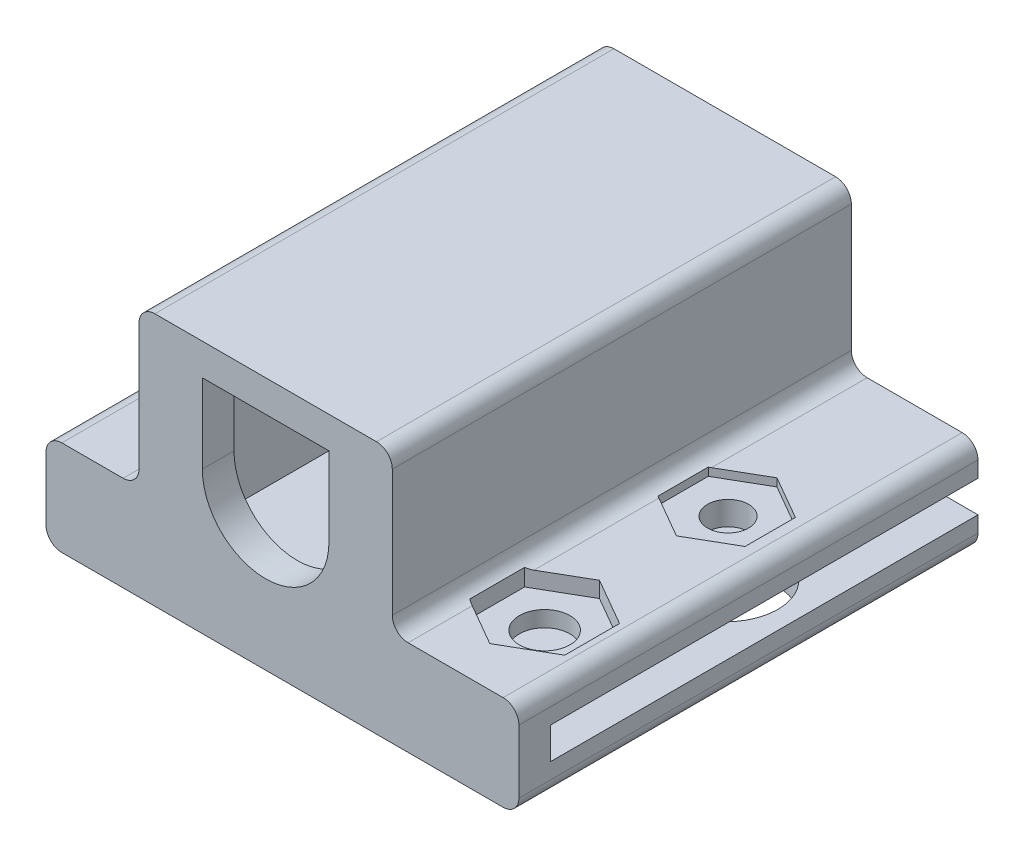
from build123d import *

# Parameters (mm, degrees)
EXTRUDE_1_DEPTH          = 2
EXTRUDE_2_DEPTH          = 27
SKETCH_4_R               = 3.227350269
CUT_EXTRUDE_1_DEPTH      = 2
CUT_EXTRUDE_2_DEPTH      = 11
CUT_EXTRUDE_2_DEPTH_BACK = 0.5
CUT_EXTRUDE_3_DEPTH      = 11
CUT_EXTRUDE_3_DEPTH_BACK = 1
SKETCH_8_W               = 12
SKETCH_8_H               = 1
EXTRUDE_3_DEPTH          = 1.6
SKETCH_10_R              = 1.6
CUT_EXTRUDE_4_DEPTH      = 6
SKETCH_11_R              = 1.3
CUT_EXTRUDE_5_DEPTH      = 6.5


with BuildPart() as part:
    # 草图1 → 凸台-拉伸1 (new body)
    with BuildSketch(Plane.XY):
        with BuildLine():
            Line((-9, -3), (-12.875, -3))
            ThreePointArc((-12.875, -3), (-13.582106781, -3.292893219), (-13.875, -4))
            Line((-13.875, -4), (-13.875, -8))
            ThreePointArc((-13.875, -8), (-13.582106781, -8.707106781), (-12.875, -9))
            Line((-12.875, -9), (15, -9))
            ThreePointArc((15, -9), (15.707106781, -8.707106781), (16, -8))
            Line((16, -8), (16, -4))
            ThreePointArc((16, -4), (15.707106781, -3.292893219), (15, -3))
            Line((15, -3), (9, -3))
            ThreePointArc((9, -3), (8.292893219, -2.707106781), (8, -2))
            Line((8, -2), (8, 6))
            ThreePointArc((8, 6), (7.707106781, 6.707106781), (7, 7))
            Line((7, 7), (-7, 7))
            ThreePointArc((-7, 7), (-7.707106781, 6.707106781), (-8, 6))
            Line((-8, 6), (-8, -2))
            ThreePointArc((-8, -2), (-8.292893219, -2.707106781), (-9, -3))
        make_face()
        with BuildLine():
            Line((-4, 5), (4, 5))
            Line((4, 5), (4, 0))
            ThreePointArc((4, 0), (0, -4), (-4, 0))
            Line((-4, 0), (-4, 5))
        make_face(mode=Mode.SUBTRACT)
    extrude(amount=EXTRUDE_1_DEPTH)

    # 草图2 → 凸台-拉伸2 (add)
    with BuildSketch(Plane(origin=(0, 0, 0), x_dir=(-1, 0, 0), z_dir=(0, 0, -1))):
        with BuildLine():
            Line((-6, 4.5), (-6, 5))
            Line((-6, 5), (-5.5, 5))
            Line((-5.5, 5), (5.5, 5))
            Line((5.5, 5), (6, 5))
            Line((6, 5), (6, 4.5))
            Line((6, 4.5), (6, -4.5))
            Line((6, -4.5), (6, -5))
            Line((6, -5), (11.875, -5))
            Line((11.875, -5), (11.875, -7))
            Line((11.875, -7), (-16, -7))
            Line((-16, -7), (-16, -8))
            ThreePointArc((-16, -8), (-15.707106781, -8.707106781), (-15, -9))
            Line((-15, -9), (12.875, -9))
            ThreePointArc((12.875, -9), (13.582106781, -8.707106781), (13.875, -8))
            Line((13.875, -8), (13.875, -4))
            ThreePointArc((13.875, -4), (13.582106781, -3.292893219), (12.875, -3))
            Line((12.875, -3), (9, -3))
            ThreePointArc((9, -3), (8.292893219, -2.707106781), (8, -2))
            Line((8, -2), (8, 6))
            ThreePointArc((8, 6), (7.707106781, 6.707106781), (7, 7))
            Line((7, 7), (-7, 7))
            ThreePointArc((-7, 7), (-7.707106781, 6.707106781), (-8, 6))
            Line((-8, 6), (-8, -2))
            ThreePointArc((-8, -2), (-8.292893219, -2.707106781), (-9, -3))
            Line((-9, -3), (-15, -3))
            ThreePointArc((-15, -3), (-15.707106781, -3.292893219), (-16, -4))
            Line((-16, -4), (-16, -5))
            Line((-16, -5), (-6, -5))
            Line((-6, -5), (-6, -4.5))
            Line((-6, -4.5), (-6, 4.5))
        make_face()
    extrude(amount=EXTRUDE_2_DEPTH)

    # 草图4 → 切除-拉伸1 (cut)
    with BuildSketch(Plane.XZ.offset(9)):
        with Locations((11.625, -15.5)):
            Circle(SKETCH_4_R)
    extrude(amount=-CUT_EXTRUDE_1_DEPTH, mode=Mode.SUBTRACT)

    # 草图5 → 切除-拉伸2 (cut, two sides)
    with BuildSketch(Plane(origin=(0, -3, 0), x_dir=(1, 0, 0), z_dir=(0, 1, 0))) as cut_extrude_2_sk:
        Polygon((11.625, 18.675426481), (8.875, 17.08771324), (8.875, 13.91228676), (11.625, 12.324573519), (14.375, 13.91228676), (14.375, 17.08771324), align=None)
    extrude(amount=CUT_EXTRUDE_2_DEPTH, mode=Mode.SUBTRACT)
    extrude(cut_extrude_2_sk.sketch, amount=-CUT_EXTRUDE_2_DEPTH_BACK, mode=Mode.SUBTRACT)

    # 草图6 → 切除-拉伸3 (cut, two sides)
    with BuildSketch(Plane(origin=(0, -3, 0), x_dir=(1, 0, 0), z_dir=(0, 1, 0))) as cut_extrude_3_sk:
        Polygon((14.625, 2.267949192), (14.625, 5.732050808), (11.625, 7.464101615), (8.625, 5.732050808), (8.625, 2.267949192), (11.625, 0.535898385), align=None)
    extrude(amount=CUT_EXTRUDE_3_DEPTH, mode=Mode.SUBTRACT)
    extrude(cut_extrude_3_sk.sketch, amount=-CUT_EXTRUDE_3_DEPTH_BACK, mode=Mode.SUBTRACT)

    # 草图8 → 凸台-拉伸3 (add)
    with BuildSketch(Plane(origin=(0, 0, -27), x_dir=(-1, 0, 0), z_dir=(0, 0, -1))):
        with Locations((0, 4.5)):
            Rectangle(SKETCH_8_W, SKETCH_8_H)
    extrude(amount=-EXTRUDE_3_DEPTH)

    # 草图10 → 切除-拉伸4 (cut, through all)
    with BuildSketch(Plane(origin=(0, -4, 0), x_dir=(1, 0, 0), z_dir=(0, 1, 0))):
        with Locations((11.625, 4)):
            Circle(SKETCH_10_R)
    extrude(amount=-CUT_EXTRUDE_4_DEPTH, mode=Mode.SUBTRACT)

    # 草图11 → 切除-拉伸5 (cut, through all)
    with BuildSketch(Plane(origin=(0, -3.5, 0), x_dir=(1, 0, 0), z_dir=(0, 1, 0))):
        with Locations((11.678753785, 15.531034762)):
            Circle(SKETCH_11_R)
    extrude(amount=-CUT_EXTRUDE_5_DEPTH, mode=Mode.SUBTRACT)


solid = part.part
